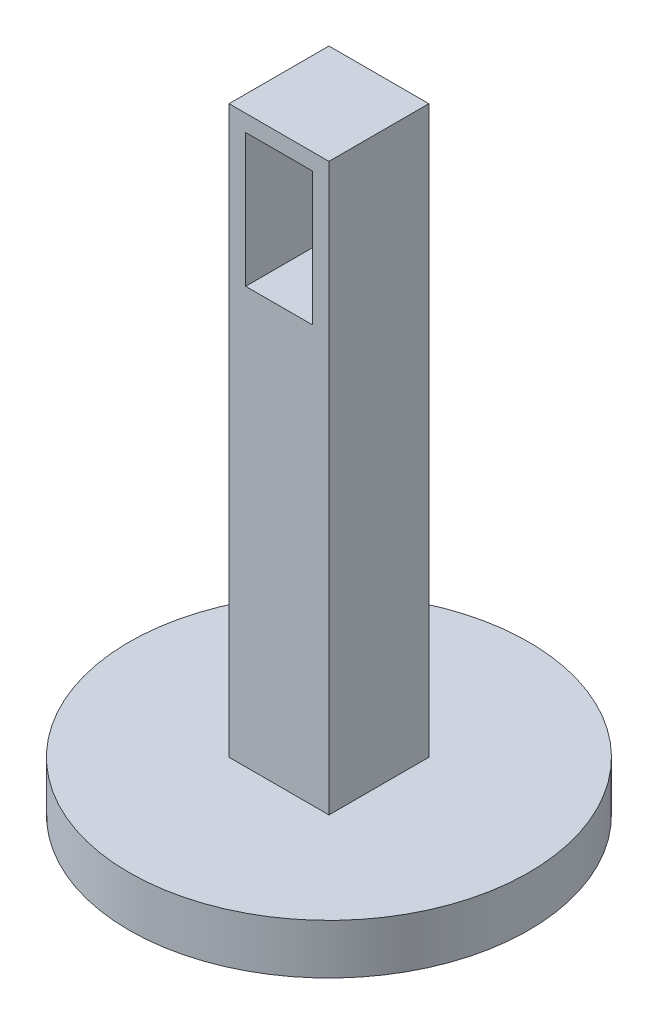
from build123d import *

# Parameters (mm, degrees)
SKETCH1_R           = 60
BOSS_EXTRUDE1_DEPTH = 15
SKETCH3_W           = 30
SKETCH3_H           = 30
BOSS_EXTRUDE2_DEPTH = 170
SKETCH4_W           = 20
SKETCH4_H           = 40
CUT_EXTRUDE1_DEPTH  = 20


with BuildPart() as part:
    # Sketch1 → Boss-Extrude1 (new body)
    with BuildSketch(Plane(origin=(0, 0, 0), x_dir=(1, 0, 0), z_dir=(0, 1, 0))):
        Circle(SKETCH1_R)
    extrude(amount=BOSS_EXTRUDE1_DEPTH)

    # Sketch3 → Boss-Extrude2 (add)
    with BuildSketch(Plane(origin=(0, 15, 0), x_dir=(1, 0, 0), z_dir=(0, 1, 0))):
        Rectangle(SKETCH3_W, SKETCH3_H)
    extrude(amount=BOSS_EXTRUDE2_DEPTH)

    # Sketch4 → Cut-Extrude1 (cut)
    with BuildSketch(Plane.XY.offset(15)):
        with Locations((0, 160)):
            Rectangle(SKETCH4_W, SKETCH4_H)
    extrude(amount=-CUT_EXTRUDE1_DEPTH, mode=Mode.SUBTRACT)


solid = part.part
